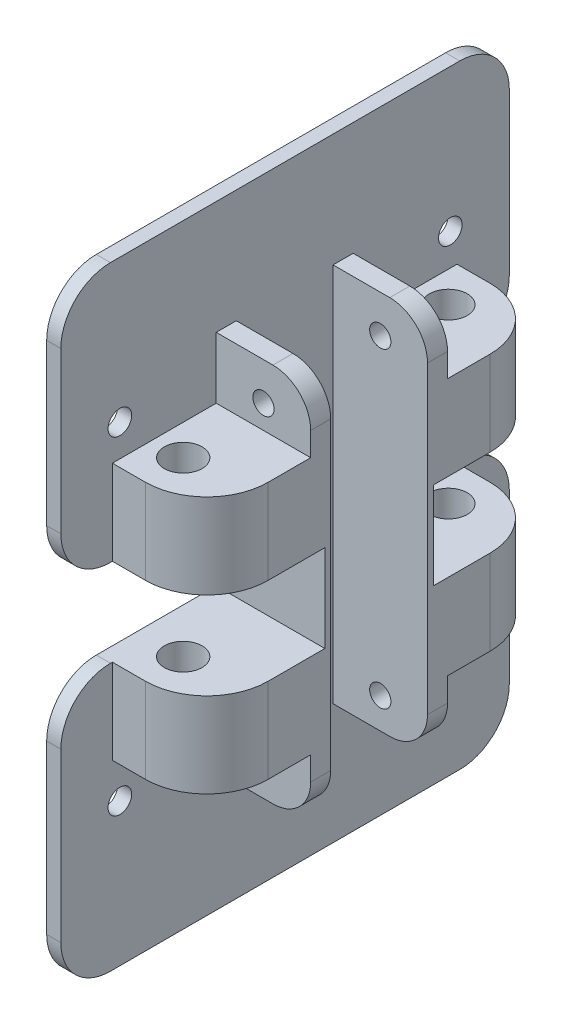
from build123d import *

# Parameters (mm, degrees)
SKETCH1_R               = 2.5
BOSS_EXTRUDE1_DEPTH     = 3
BOSS_EXTRUDE2_DEPTH     = 23
FILLET1_R               = 13
FILLET2_R               = 8
CUT_EXTRUDE1_DEPTH      = 106.629068292
CUT_EXTRUDE1_DEPTH_BACK = 106.629068292
SKETCH2_R               = 4
CUT_EXTRUDE2_DEPTH      = 93.669410672
CUT_EXTRUDE2_DEPTH_BACK = 93.669410672
SKETCH3_R               = 2.25


with BuildPart() as part:
    # Sketch1 → Boss-Extrude1 (new body)
    with BuildSketch(Plane(origin=(0, 0, 0), x_dir=(0, 0, -1), z_dir=(1, 0, 0))):
        with BuildLine():
            ThreePointArc((47.5, 54.5), (44.424621202, 61.924621202), (37, 65))
            Line((37, 65), (-37, 65))
            ThreePointArc((-37, 65), (-44.424621202, 61.924621202), (-47.5, 54.5))
            Line((-47.5, 54.5), (-47.5, 20.500000268))
            ThreePointArc((-47.5, 20.500000268), (-44.424621202, 13.075379066), (-37, 10.000000268))
            Line((-37, 10.000000268), (-11.583769402, 10.000000268))
            Line((-11.583769402, 10.000000268), (-11.583769402, -8.500000373))
            Line((-11.583769402, -8.500000373), (-37, -8.500000373))
            ThreePointArc((-37, -8.500000373), (-44.424621202, -11.57537917), (-47.5, -19.000000373))
            Line((-47.5, -19.000000373), (-47.5, -54.5))
            ThreePointArc((-47.5, -54.5), (-44.424621202, -61.924621202), (-37, -65))
            Line((-37, -65), (37, -65))
            ThreePointArc((37, -65), (44.424621202, -61.924621202), (47.5, -54.5))
            Line((47.5, -54.5), (47.5, -19.000000373))
            ThreePointArc((47.5, -19.000000373), (44.424621202, -11.57537917), (37, -8.500000373))
            Line((37, -8.500000373), (11.416231668, -8.500000373))
            Line((11.416231668, -8.500000373), (11.416231668, 10.000000268))
            Line((11.416231668, 10.000000268), (37, 10.000000268))
            ThreePointArc((37, 10.000000268), (44.424621202, 13.075379066), (47.5, 20.500000268))
            Line((47.5, 20.500000268), (47.5, 54.5))
        make_face()
        with Locations((-35, -34.75)):
            Circle(SKETCH1_R, mode=Mode.SUBTRACT)
        with Locations((35, -34.75)):
            Circle(SKETCH1_R, mode=Mode.SUBTRACT)
        with Locations((-35, 34.75)):
            Circle(SKETCH1_R, mode=Mode.SUBTRACT)
        with Locations((35, 34.75)):
            Circle(SKETCH1_R, mode=Mode.SUBTRACT)
    extrude(amount=BOSS_EXTRUDE1_DEPTH)

    # Sketch1_3 → Boss-Extrude2 (add)
    with BuildSketch(Plane(origin=(0, 0, 0), x_dir=(0, 0, -1), z_dir=(1, 0, 0))):
        Polygon((11.416231668, 10.000000268), (36.416231105, 10.000000268), (36.416231105, 28.000000268), (14.416231105, 28.000000268), (14.416231105, 41.000000268), (10.166231386, 41.000000268), (10.166231386, -39.500000373), (14.416231105, -39.500000373), (14.416231105, -26.500000373), (36.416231105, -26.500000373), (36.416231105, -8.500000373), (11.416231668, -8.500000373), align=None)
        Polygon((-36.583768839, 28.000000268), (-36.583768839, 10.000000268), (-11.583769402, 10.000000268), (-11.583769402, -8.500000373), (-36.583768839, -8.500000373), (-36.583768839, -26.500000373), (-14.583768839, -26.500000373), (-14.583768839, -39.500000373), (-10.33376912, -39.500000373), (-10.33376912, 41.000000268), (-14.583768839, 41.000000268), (-14.583768839, 28.000000268), align=None)
    extrude(amount=BOSS_EXTRUDE2_DEPTH)

    # Fillet1
    fillet1_edges = [part.edges().sort_by_distance(p)[0] for p in [
        (23, 19.000000268, -36.416231105),
        (23, -17.500000373, -36.416231105),
        (23, -17.500000373, 36.583768839),
        (23, 19.000000268, 36.583768839),
    ]]
    fillet(fillet1_edges, radius=FILLET1_R)

    # Fillet2
    fillet2_edges = [part.edges().sort_by_distance(p)[0] for p in [
        (23, 41.000000268, 12.45876898),
        (23, 41.000000268, -12.291231246),
        (23, -39.500000373, -12.291231246),
        (23, -39.500000373, 12.45876898),
    ]]
    fillet(fillet2_edges, radius=FILLET2_R)

    # Sketch2 → Cut-Extrude1 (cut, two sides: drawn at the far end of the back side and taken through both)
    with BuildSketch(Plane.XZ.offset(26.500000373).offset(-CUT_EXTRUDE1_DEPTH_BACK)):
        with Locations((9.5, 28.083768839)):
            Circle(SKETCH2_R)
        with Locations((9.5, -28.083768839)):
            Circle(SKETCH2_R)
    extrude(amount=CUT_EXTRUDE1_DEPTH + CUT_EXTRUDE1_DEPTH_BACK, mode=Mode.SUBTRACT)

    # Sketch3 → Cut-Extrude2 (cut, two sides: drawn at the far end of the back side and taken through both)
    with BuildSketch(Plane(origin=(0, 0, -14.416231105), x_dir=(-1, 0, 0), z_dir=(0, 0, -1)).offset(-CUT_EXTRUDE2_DEPTH_BACK)):
        with Locations((-13, -33.000000373)):
            Circle(SKETCH3_R)
        with Locations((-13, 33.000000373)):
            Circle(SKETCH3_R)
    extrude(amount=CUT_EXTRUDE2_DEPTH + CUT_EXTRUDE2_DEPTH_BACK, mode=Mode.SUBTRACT)


solid = part.part
